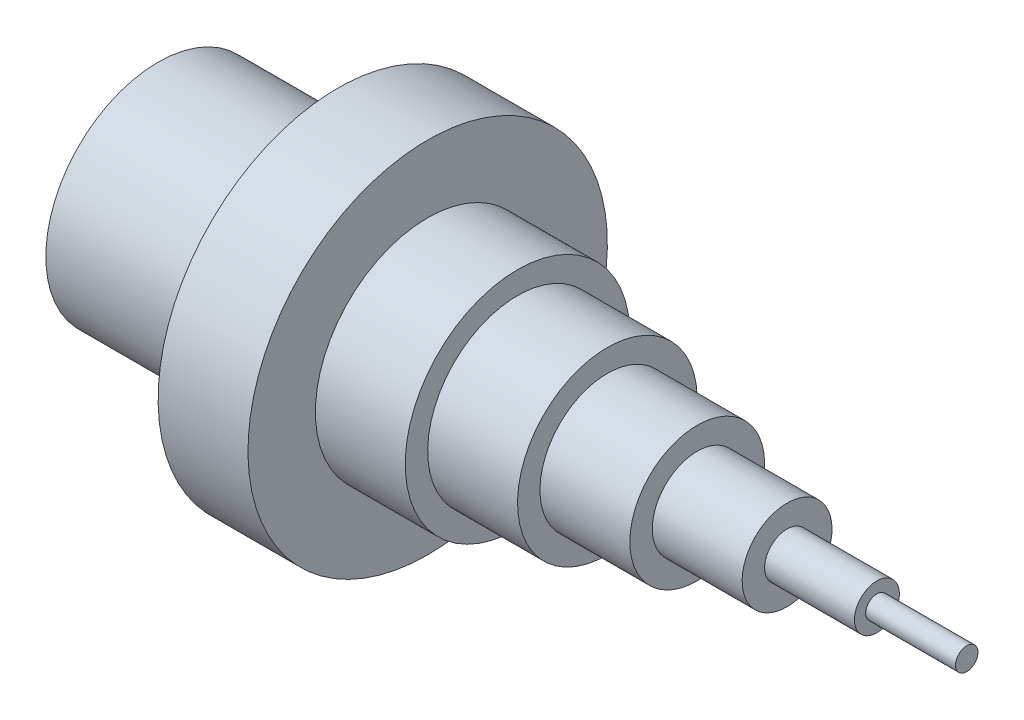
from build123d import *

# Parameters (mm, degrees)
SKETCH3_R          = 20
CUT_EXTRUDE2_DEPTH = 40


with BuildPart() as part:
    # Sketch2 → Revolve1 (revolve)
    with BuildSketch(Plane.XY, mode=Mode.PRIVATE) as revolve1_sk:
        Polygon((60, 40), (60, 25), (80, 25), (80, 20), (100, 20), (100, 15), (120, 15), (120, 10), (140, 10), (140, 5), (160, 5), (160, 2.5), (180, 2.5), (180, 0), (0, 0), (0, 25), (40, 25), (40, 40), align=None)
    revolve(revolve1_sk.sketch.rotate(Axis((0, 0, 0), (1, 0, 0)), 180), axis=Axis((0, 0, 0), (1, 0, 0)))  # turned: the seam where the file's is

    # Sketch3 → Cut-Extrude2 (cut)
    with BuildSketch(Plane.ZY):
        with Locations(Location((0, 0, 0), (0, 0, 270))):  # turned: the seam where the file's is
            Circle(SKETCH3_R)
    extrude(amount=-CUT_EXTRUDE2_DEPTH, mode=Mode.SUBTRACT)


solid = part.part
